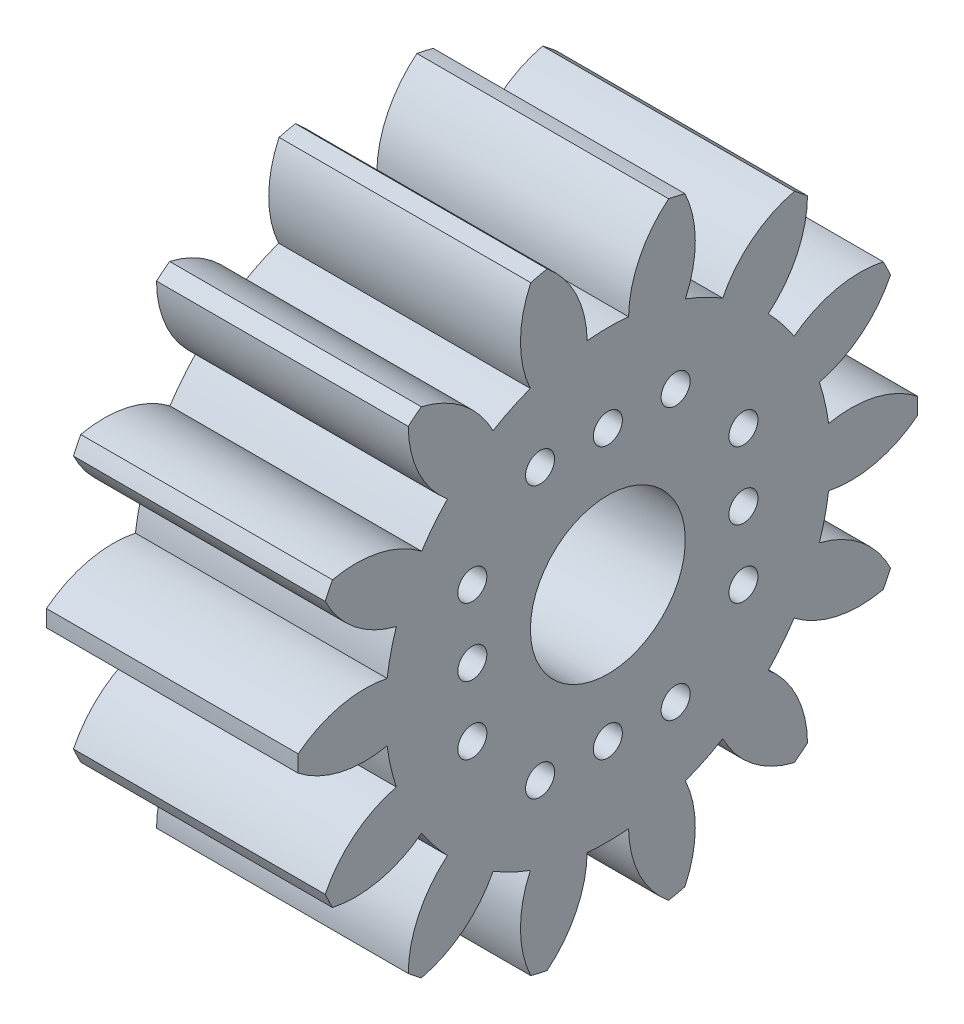
from build123d import *

# Parameters (mm, degrees)
BASPROSKE_W        = 13
BASPROSKE_H        = 16
TOOTHCUT_DEPTH     = 27.095976701
TEETHCUTS_COUNT    = 14
TEETHCUTS_ANGLE    = 334.285714286
BORSKE_R           = 4
BORE_DEPTH         = 50.0005588
SKETCH2_R          = 0.75
CUT_EXTRUDE1_DEPTH = 6
CIRPATTERN1_COUNT  = 4


with BuildPart() as part:
    # BasProSke → Base-Revolve (revolve)
    with BuildSketch(Plane(origin=(0, 0, 0), x_dir=(1, 0, 0), z_dir=(0, 1, 0)), mode=Mode.PRIVATE) as base_revolve_sk:
        with Locations((6.5, 8)):
            Rectangle(BASPROSKE_W, BASPROSKE_H)
    revolve(base_revolve_sk.sketch.rotate(Axis((-10, 0, 0), (1, 0, 0)), 180), axis=Axis((-10, 0, 0), (1, 0, 0)))

    # TooCutSke → ToothCut (cut, through all)
    with BuildSketch(Plane(origin=(0, 0, 0), x_dir=(0, 0, -1), z_dir=(1, 0, 0))):
        with BuildLine():
            ThreePointArc((1.067858192, 11.449309144), (0, 11.499), (-1.067858192, 11.449309144))
            ThreePointArc((-1.067858192, 11.449309144), (-1.641684211, 13.812780716), (-3.163375005, 15.710076503))
            ThreePointArc((-3.163375005, 15.710076503), (0, 16.0254), (3.163375005, 15.710076503))
            ThreePointArc((3.163375005, 15.710076503), (1.641684211, 13.812780716), (1.067858192, 11.449309144))
        make_face()
    toothcut = extrude(amount=TOOTHCUT_DEPTH, mode=Mode.SUBTRACT)

    # TeethCuts: ToothCut ×14 about axis
    teethcuts_axis = Axis((-10, 0, 0), (1, 0, 0))
    for i in range(1, TEETHCUTS_COUNT):
        add(toothcut.rotate(teethcuts_axis, i * TEETHCUTS_ANGLE / (TEETHCUTS_COUNT - 1)), mode=Mode.SUBTRACT)

    # BorSke → Bore (cut, symmetric)
    with BuildSketch(Plane(origin=(0, 0, 0), x_dir=(0, 0, -1), z_dir=(1, 0, 0))):
        with Locations(Location((0, 0, 0), (0, 0, 180))):
            Circle(BORSKE_R)
    extrude(amount=BORE_DEPTH, both=True, mode=Mode.SUBTRACT)

    # Sketch2 → Cut-Extrude1 (cut)
    with BuildSketch(Plane(origin=(13, 0, 0), x_dir=(0, 0, -1), z_dir=(1, 0, 0))):
        with Locations((-3.5, 7)):
            Circle(SKETCH2_R)
        with Locations((0, 7)):
            Circle(SKETCH2_R)
        with Locations((3.5, 7)):
            Circle(SKETCH2_R)
    cut_extrude1 = extrude(amount=-CUT_EXTRUDE1_DEPTH, mode=Mode.SUBTRACT)

    # CirPattern1: Cut-Extrude1 ×4 about axis
    cirpattern1_axis = Axis((0, 0, 0), (1, 0, 0))
    for i in range(1, CIRPATTERN1_COUNT):
        add(cut_extrude1.rotate(cirpattern1_axis, i * 360 / CIRPATTERN1_COUNT), mode=Mode.SUBTRACT)


solid = part.part
